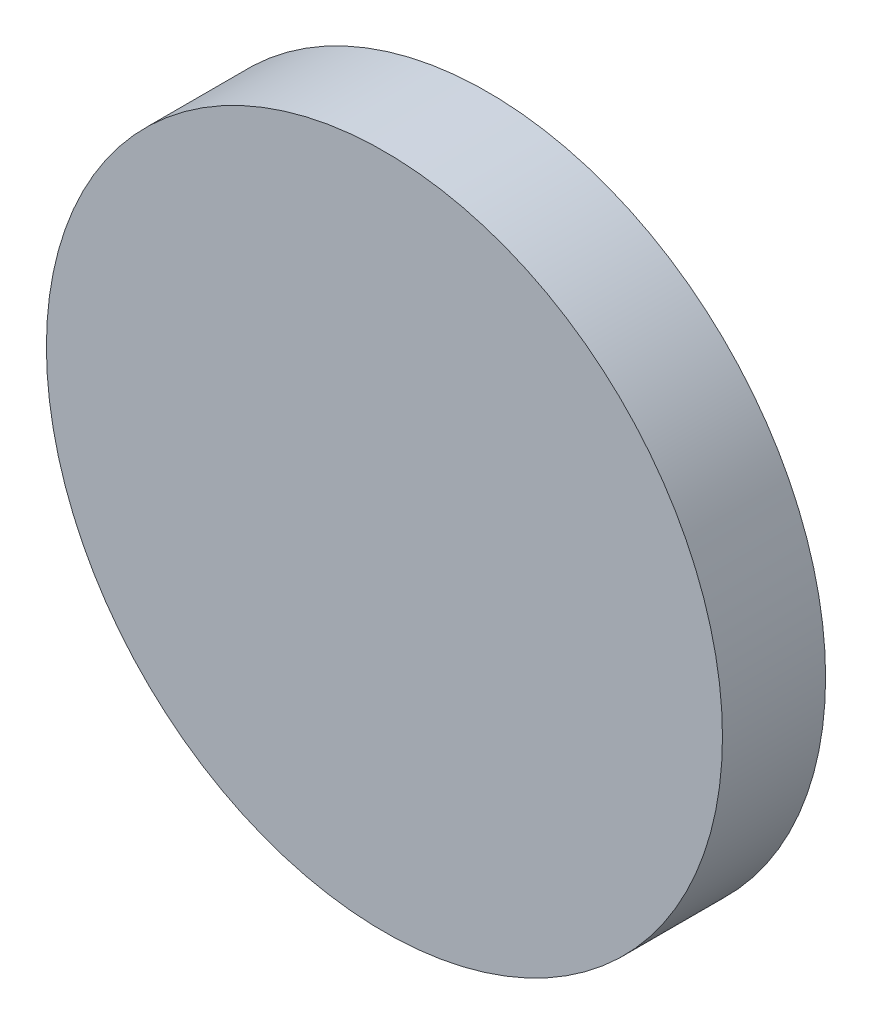
from build123d import *

# Parameters (mm, degrees)
SKETCH1_R           = 2.95
BOSS_EXTRUDE1_DEPTH = 0.9


with BuildPart() as part:
    # Sketch1 → Boss-Extrude1 (new body)
    with BuildSketch(Plane.XY):
        Circle(SKETCH1_R)
    extrude(amount=BOSS_EXTRUDE1_DEPTH)


solid = part.part
